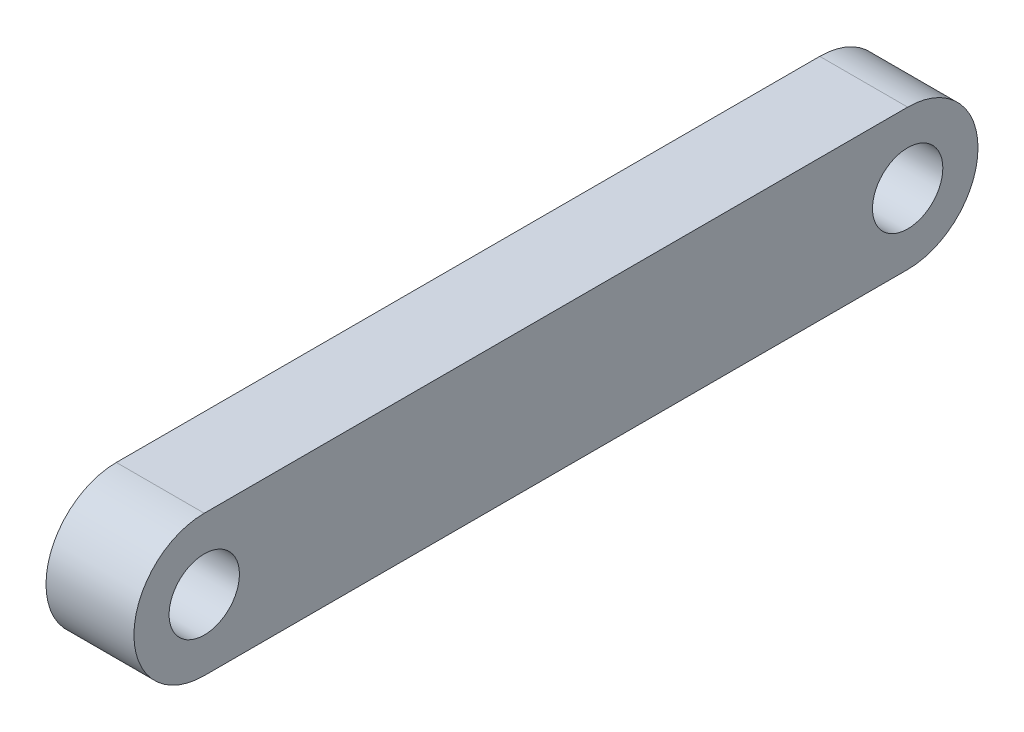
from build123d import *

# Parameters (mm, degrees)
SKETCH_1_R      = 4
EXTRUDE_1_DEPTH = 10


with BuildPart() as part:
    # 草图1 → 凸台-拉伸1 (new body)
    with BuildSketch(Plane(origin=(0, 0, 0), x_dir=(0, 0, -1), z_dir=(1, 0, 0))):
        with BuildLine():
            Line((-40, 8), (40, 8))
            ThreePointArc((40, 8), (48, 0), (40, -8))
            Line((40, -8), (-40, -8))
            ThreePointArc((-40, -8), (-48, 0), (-40, 8))
        make_face()
        with Locations((40, 0)):
            Circle(SKETCH_1_R, mode=Mode.SUBTRACT)
        with Locations((-40, 0)):
            Circle(SKETCH_1_R, mode=Mode.SUBTRACT)
    extrude(amount=EXTRUDE_1_DEPTH)


solid = part.part
